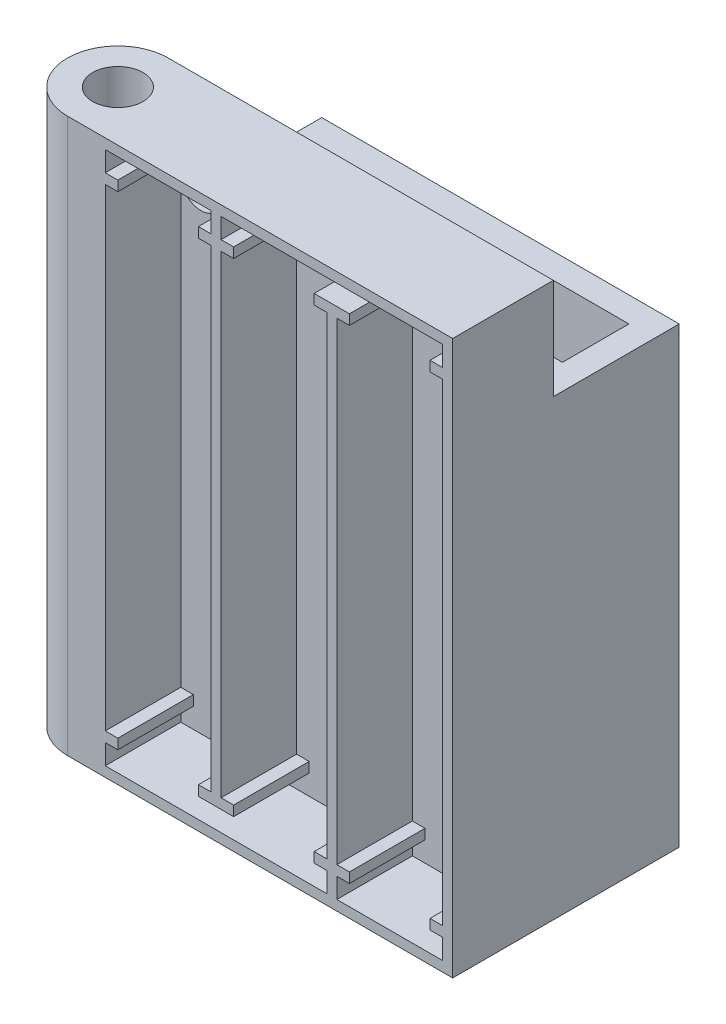
from build123d import *

# Parameters (mm, degrees)
SKETCH1_W           = 30.5
SKETCH1_H           = 10
BOSS_EXTRUDE1_DEPTH = 2.5
SKETCH2_W           = 35.5
SKETCH2_H           = 15
BOSS_EXTRUDE3_DEPTH = 45
SKETCH3_W           = 7.5
SKETCH3_H           = 3.4
CUT_EXTRUDE1_DEPTH  = 29
SKETCH4_W           = 35.5
SKETCH4_H           = 2.5
BOSS_EXTRUDE4_DEPTH = 10
SKETCH5_W           = 35.5
SKETCH5_H           = 55
SKETCH5_W_2         = 33.5
SKETCH5_H_2         = 53
BOSS_EXTRUDE5_DEPTH = 7.5
SKETCH6_W           = 10.5
SKETCH6_H           = 47
BOSS_EXTRUDE6_DEPTH = 7.5
SKETCH7_W           = 8
SKETCH7_H           = 1
SKETCH7_W_2         = 1
SKETCH7_H_2         = 2
CUT_EXTRUDE2_DEPTH  = 7.5
SKETCH8_W           = 1.6
SKETCH8_H           = 46
SKETCH8_H_2         = 9
CUT_EXTRUDE3_DEPTH  = 2.5
CUT_EXTRUDE4_REACH  = 17
SKETCH9_R           = 1
SKETCH10_R          = 2
CUT_EXTRUDE5_DEPTH  = 1
SKETCH11_R          = 2.5
BOSS_EXTRUDE8_DEPTH = 55


with BuildPart() as part:
    # Sketch1 → Boss-Extrude1 (new body)
    with BuildSketch(Plane(origin=(0, 0, 0), x_dir=(1, 0, 0), z_dir=(0, 1, 0))):
        Rectangle(SKETCH1_W, SKETCH1_H)
    extrude(amount=BOSS_EXTRUDE1_DEPTH)

    # Sketch2 → Boss-Extrude3 (add)
    with BuildSketch(Plane(origin=(0, 0, 0), x_dir=(1, 0, 0), z_dir=(0, 1, 0))):
        Rectangle(SKETCH2_W, SKETCH2_H)
        Polygon((-15.25, 5), (-15.25, -5), (-10.25, -5), (-10.25, -1.6), (15.25, -1.6), (15.25, 5), align=None, mode=Mode.SUBTRACT)
    extrude(amount=BOSS_EXTRUDE3_DEPTH)

    # Sketch3 → Cut-Extrude1 (cut)
    with BuildSketch(Plane(origin=(0, 45, 0), x_dir=(1, 0, 0), z_dir=(0, 1, 0))):
        with Locations((-6.5, -3.3)):
            Rectangle(SKETCH3_W, SKETCH3_H)
    extrude(amount=-CUT_EXTRUDE1_DEPTH, mode=Mode.SUBTRACT)

    # Sketch4 → Boss-Extrude4 (add)
    with BuildSketch(Plane(origin=(0, 45, 0), x_dir=(1, 0, 0), z_dir=(0, 1, 0))):
        with Locations((0, -6.25)):
            Rectangle(SKETCH4_W, SKETCH4_H)
    extrude(amount=BOSS_EXTRUDE4_DEPTH)

    # Sketch5 → Boss-Extrude5 (add)
    with BuildSketch(Plane.XY.offset(7.5)):
        with Locations((0, 27.5)):
            Rectangle(SKETCH5_W, SKETCH5_H)
        with Locations((0, 27.5)):
            Rectangle(SKETCH5_W_2, SKETCH5_H_2, mode=Mode.SUBTRACT)
    extrude(amount=BOSS_EXTRUDE5_DEPTH)

    # Sketch6 → Boss-Extrude6 (add)
    with BuildSketch(Plane.XY.offset(7.5)):
        Polygon((-6.25, 54), (-6.25, 52), (-16.75, 52), (-16.75, 51), (-6.25, 51), (-6.25, 4), (-16.75, 4), (-16.75, 3), (-6.25, 3), (-6.25, 1), (-5.25, 1), (-5.25, 3), (5.25, 3), (5.25, 1), (6.25, 1), (6.25, 3), (16.75, 3), (16.75, 4), (6.25, 4), (6.25, 51), (16.75, 51), (16.75, 52), (6.25, 52), (6.25, 54), (5.25, 54), (5.25, 52), (-5.25, 52), (-5.25, 54), align=None)
        with Locations((0, 27.5)):
            Rectangle(SKETCH6_W, SKETCH6_H, mode=Mode.SUBTRACT)
    extrude(amount=BOSS_EXTRUDE6_DEPTH)

    # Sketch7 → Cut-Extrude2 (cut)
    with BuildSketch(Plane.XY.offset(15)):
        with Locations((0, 51.5)):
            Rectangle(SKETCH7_W, SKETCH7_H)
        with Locations((-11.5, 51.5)):
            Rectangle(SKETCH7_W, SKETCH7_H)
        with Locations((11.5, 51.5)):
            Rectangle(SKETCH7_W, SKETCH7_H)
        with Locations((11.5, 3.5)):
            Rectangle(SKETCH7_W, SKETCH7_H)
        with Locations((5.75, 53)):
            Rectangle(SKETCH7_W_2, SKETCH7_H_2)
        with Locations((0, 3.5)):
            Rectangle(SKETCH7_W, SKETCH7_H)
        with Locations((-11.5, 3.5)):
            Rectangle(SKETCH7_W, SKETCH7_H)
        with Locations((-5.75, 2)):
            Rectangle(SKETCH7_W_2, SKETCH7_H_2)
    extrude(amount=-CUT_EXTRUDE2_DEPTH, mode=Mode.SUBTRACT)

    # Sketch8 → Cut-Extrude3 (cut)
    with BuildSketch(Plane.XY.offset(7.5)):
        with Locations((11.5, 24)):
            Rectangle(SKETCH8_W, SKETCH8_H)
        with Locations((-11.5, 49.5)):
            Rectangle(SKETCH8_W, SKETCH8_H_2)
    extrude(amount=-CUT_EXTRUDE3_DEPTH, mode=Mode.SUBTRACT)

    # Sketch9 → Cut-Extrude4 (cut, up to next)
    with BuildSketch(Plane.XY.offset(7.5), mode=Mode.PRIVATE) as cut_extrude4_sk1:
        with Locations((-14.75, 48)):
            Circle(SKETCH9_R)
    cut_extrude4_tool1 = extrude(cut_extrude4_sk1.sketch, amount=-CUT_EXTRUDE4_REACH, mode=Mode.PRIVATE) & part.part
    add(cut_extrude4_tool1.solids().sort_by_distance((-14.75, 48, 7.5))[0], mode=Mode.SUBTRACT)
    # Sketch9 → Cut-Extrude4 (cut, up to next)
    with BuildSketch(Plane.XY.offset(7.5), mode=Mode.PRIVATE) as cut_extrude4_sk2:
        with Locations((14.75, 48)):
            Circle(SKETCH9_R)
    cut_extrude4_tool2 = extrude(cut_extrude4_sk2.sketch, amount=-CUT_EXTRUDE4_REACH, mode=Mode.PRIVATE) & part.part
    add(cut_extrude4_tool2.solids().sort_by_distance((14.75, 48, 7.5))[0], mode=Mode.SUBTRACT)

    # Sketch10 → Cut-Extrude5 (cut)
    with BuildSketch(Plane.XY.offset(7.5)):
        with Locations((-14.75, 48)):
            Circle(SKETCH10_R)
        with Locations((14.75, 48)):
            Circle(SKETCH10_R)
    extrude(amount=-CUT_EXTRUDE5_DEPTH, mode=Mode.SUBTRACT)

    # Sketch11 → Boss-Extrude8 (add)
    with BuildSketch(Plane(origin=(0, 55, 0), x_dir=(1, 0, 0), z_dir=(0, 1, 0))):
        with BuildLine():
            Line((-17.75, -5), (-20.5, -5))
            ThreePointArc((-20.5, -5), (-25.5, -10), (-20.5, -15))
            Line((-20.5, -15), (-17.75, -15))
            Line((-17.75, -15), (-17.75, -5))
        make_face()
        with Locations((-20.5, -10)):
            Circle(SKETCH11_R, mode=Mode.SUBTRACT)
    extrude(amount=-BOSS_EXTRUDE8_DEPTH)


solid = part.part
